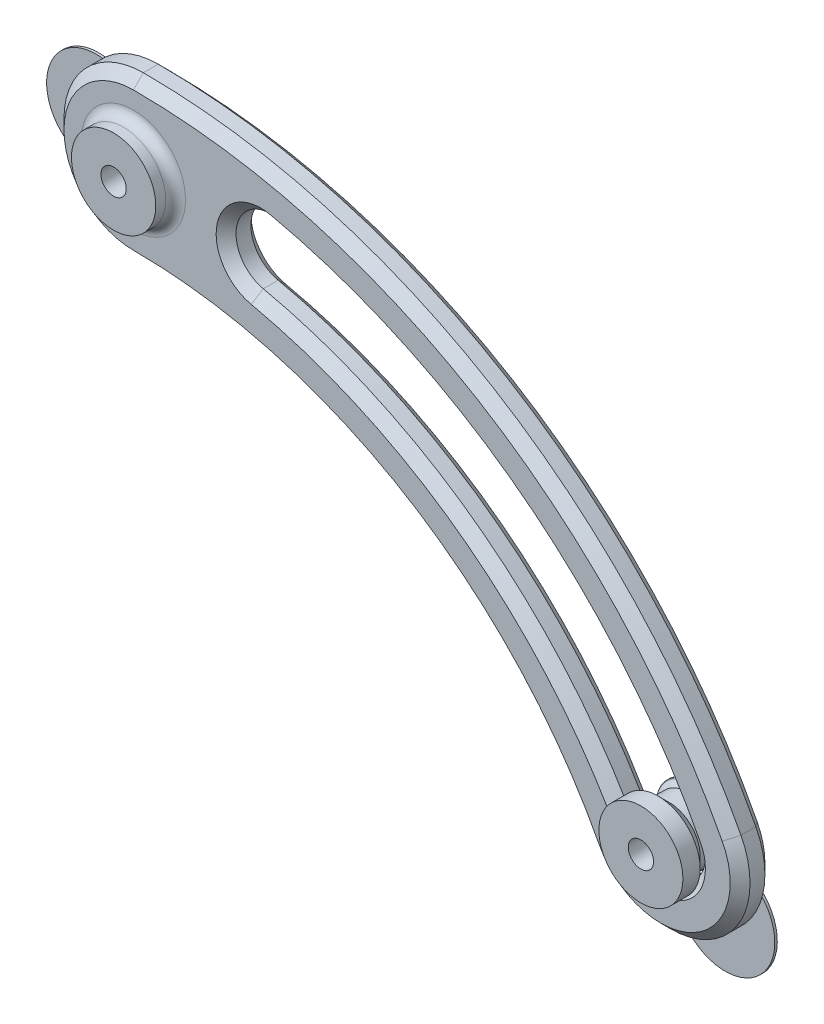
from build123d import *

# Parameters (mm, degrees)
SKETCH1_R           = 8.5
SKETCH1_R_2         = 2.55
BOSS_EXTRUDE1_DEPTH = 7
BOSS_EXTRUDE2_START = 7
SKETCH1_3_R         = 8.5
SKETCH1_3_R_2       = 2.55
BOSS_EXTRUDE2_DEPTH = 4
CHAMFER1_SIZE       = 2
FILLET2_R           = 2
CUT_EXTRUDE1_START  = -9
SKETCH2_R           = 4.75
CUT_EXTRUDE1_DEPTH  = 2
CHAMFER2_SIZE       = 0.75
CHAMFER2_SIZE2      = 0.672431604
FILLET3_R           = 0.5
SKETCH4_R           = 8.469669914
BOSS_EXTRUDE4_DEPTH = 3.46967
SKETCH5_R           = 2.55
CUT_EXTRUDE2_DEPTH  = 11
SKETCH7_R           = 2.55
BOSS_EXTRUDE5_DEPTH = 0.5
BOSS_EXTRUDE6_DEPTH = 0.5


with BuildPart() as part:
    # Sketch1 → Boss-Extrude1 (new body)
    with BuildSketch(Plane.XY):
        with BuildLine():
            ThreePointArc((92.127210642, -71.744668074), (53.839787702, -31.020916727), (0, -16))
            ThreePointArc((0, -16), (-16, 0), (0, 16))
            ThreePointArc((0, 16), (70.405876226, -3.642737258), (120.474044686, -56.896873635))
            ThreePointArc((120.474044686, -56.896873635), (113.724524883, -78.494187876), (92.127210642, -71.744668074))
        make_face()
        Circle(SKETCH1_R, mode=Mode.SUBTRACT)
        with BuildLine():
            ThreePointArc((112.501497611, -61.072815821), (77.057279191, -19.048646747), (27.173726746, 4.058810952))
            ThreePointArc((27.173726746, 4.058810952), (18.838075062, -1.2813118), (24.178197814, -9.616963484))
            ThreePointArc((24.178197814, -9.616963484), (68.562775973, -30.177142381), (100.099757717, -67.568725888))
            ThreePointArc((100.099757717, -67.568725888), (109.548582697, -70.521640801), (112.501497611, -61.072815821))
        make_face(mode=Mode.SUBTRACT)
        Circle(SKETCH1_R)
        Circle(SKETCH1_R_2, mode=Mode.SUBTRACT)
    extrude(amount=BOSS_EXTRUDE1_DEPTH)

    # Sketch1_3 → Boss-Extrude2 (add)
    with BuildSketch(Plane.XY.offset(BOSS_EXTRUDE2_START)):
        Circle(SKETCH1_3_R)
        Circle(SKETCH1_3_R_2, mode=Mode.SUBTRACT)
    extrude(amount=BOSS_EXTRUDE2_DEPTH)

    # Chamfer1
    chamfer1_edges = [part.edges().sort_by_distance(p)[0] for p in [
        (113.724524883, -78.494187876, 7),
        (18.838075062, -1.2813118, 0),
        (68.562775973, -30.177142381, 0),
        (109.548582697, -70.521640801, 0),
        (77.057279191, -19.048646747, 0),
        (-16, 0, 0),
        (70.405876226, -3.642737258, 0),
        (113.724524883, -78.494187876, 0),
        (70.405876226, -3.642737258, 7),
        (53.839787702, -31.020916727, 0),
        (-16, 0, 7),
        (77.057279191, -19.048646747, 7),
        (109.548582697, -70.521640801, 7),
        (68.562775973, -30.177142381, 7),
        (18.838075062, -1.2813118, 7),
        (53.839787702, -31.020916727, 7),
    ]]
    chamfer(chamfer1_edges, length=CHAMFER1_SIZE)

    # Fillet2
    fillet2_edges = [part.edges().sort_by_distance(p)[0] for p in [
        (-8.5, 0, 7),
    ]]
    fillet(fillet2_edges, radius=FILLET2_R)

    # Sketch2 → Cut-Extrude1 (cut)
    with BuildSketch(Plane.XY.offset(11).offset(CUT_EXTRUDE1_START)):
        Circle(SKETCH2_R)
    extrude(amount=-CUT_EXTRUDE1_DEPTH, mode=Mode.SUBTRACT)

    # Sketch7 → Boss-Extrude5 (add)
    with BuildSketch(Plane(origin=(0, 0, 2), x_dir=(-1, 0, 0), z_dir=(0, 0, -1))):
        Circle(SKETCH7_R)
    extrude(amount=-BOSS_EXTRUDE5_DEPTH)

    # Sketch8 → Boss-Extrude6 (add)
    with BuildSketch(Plane(origin=(0, 0, 0), x_dir=(-1, 0, 0), z_dir=(0, 0, -1))):
        with BuildLine():
            ThreePointArc((10.428571429, -9.340497736), (24, 0), (10.428571429, 9.340497736))
            ThreePointArc((10.428571429, 9.340497736), (14, 0), (10.428571429, -9.340497736))
        make_face()
        with BuildLine():
            ThreePointArc((-119.413590916, -69.224870643), (-117.436473493, -85.580896387), (-102.865244715, -77.89273254))
            ThreePointArc((-102.865244715, -77.89273254), (-112.796537731, -76.722510748), (-119.413590916, -69.224870643))
        make_face()
    extrude(amount=-BOSS_EXTRUDE6_DEPTH)


with BuildPart() as body_2:
    # Sketch3 → Revolve1 (revolve)
    with BuildSketch(Plane(origin=(49.322808384, -94.165195348, 0), x_dir=(-0.885838564, -0.463993576, 0), z_dir=(0.463993576, -0.885838564, 0))):
        Polygon((-55.85110094, -7.530330086), (-58.070770854, -5.310660172), (-58.070770854, -1.689339828), (-56.381431026, 0), (-64.320770854, 0), (-64.320770854, -7.530330086), align=None)
    revolve(axis=Axis((106.300627664, -64.320770854, 5), (0, 0, -1)))

    # Chamfer2
    chamfer2_edges = [body_2.edges().sort_by_distance(p)[0] for p in [
        (113.333601055, -60.636968174, 0),
    ]]
    chamfer2_side = [body_2.faces().sort_by_distance(p)[0] for p in [
        (112.585359872, -61.028889589, 0.844669914),
    ]]
    chamfer(chamfer2_edges, length=CHAMFER2_SIZE, length2=CHAMFER2_SIZE2, reference=chamfer2_side[0])

    # Fillet3
    fillet3_edges = [body_2.edges().sort_by_distance(p)[0] for p in [
        (112.863814214, -60.883037928, 0.530330086),
    ]]
    fillet(fillet3_edges, radius=FILLET3_R)

    # Sketch4 → Boss-Extrude4 (add)
    with BuildSketch(Plane.XY.offset(7.530330086)):
        with Locations((106.300627664, -64.320770854)):
            Circle(SKETCH4_R)
    extrude(amount=BOSS_EXTRUDE4_DEPTH)

    # Sketch5 → Cut-Extrude2 (cut)
    with BuildSketch(Plane.XY.offset(11)):
        with Locations((106.300627664, -64.320770854)):
            Circle(SKETCH5_R)
    extrude(amount=-CUT_EXTRUDE2_DEPTH, mode=Mode.SUBTRACT)


solid = Compound([part.part, body_2.part])
